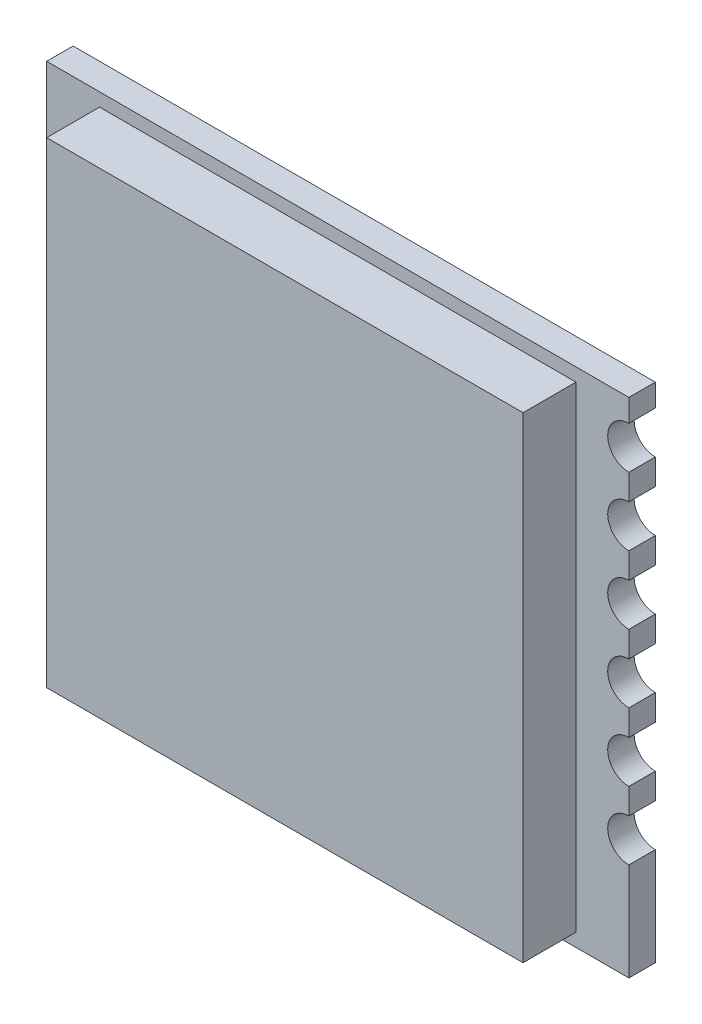
from build123d import *

# Parameters (mm, degrees)
SKETCH_1_W          = 22
SKETCH_1_H          = 19
EXTRUDE_1_DEPTH     = 1
SKETCH_2_W          = 18
SKETCH_2_H          = 18
EXTRUDE_2_DEPTH     = 2
CUT_EXTRUDE_1_DEPTH = 4


with BuildPart() as part:
    # Эскиз1 → Бобышка-Вытянуть1 (new body)
    with BuildSketch(Plane.XY):
        Rectangle(SKETCH_1_W, SKETCH_1_H)
    extrude(amount=EXTRUDE_1_DEPTH)

    # Эскиз2 → Бобышка-Вытянуть2 (add)
    with BuildSketch(Plane.XY.offset(1)):
        Rectangle(SKETCH_2_W, SKETCH_2_H)
    extrude(amount=EXTRUDE_2_DEPTH)

    # Эскиз3 → Вырез-Вытянуть1 (cut, through all)
    with BuildSketch(Plane.XY.offset(3)):
        with BuildLine():
            Line((-11, -4.2), (-11, -5.8))
            ThreePointArc((-11, -5.8), (-10.2, -5), (-11, -4.2))
        make_face()
        with BuildLine():
            Line((-11, -1.63), (-11, -3.23))
            ThreePointArc((-11, -3.23), (-10.2, -2.43), (-11, -1.63))
        make_face()
        with BuildLine():
            Line((-11, 0.94), (-11, -0.66))
            ThreePointArc((-11, -0.66), (-10.2, 0.14), (-11, 0.94))
        make_face()
        with BuildLine():
            Line((-11, 3.51), (-11, 1.91))
            ThreePointArc((-11, 1.91), (-10.2, 2.71), (-11, 3.51))
        make_face()
        with BuildLine():
            Line((-11, 6.08), (-11, 4.48))
            ThreePointArc((-11, 4.48), (-10.2, 5.28), (-11, 6.08))
        make_face()
        with BuildLine():
            Line((11, -4.2), (11, -5.8))
            ThreePointArc((11, -5.8), (10.2, -5), (11, -4.2))
        make_face()
        with BuildLine():
            Line((11, -1.63), (11, -3.23))
            ThreePointArc((11, -3.23), (10.2, -2.43), (11, -1.63))
        make_face()
        with BuildLine():
            Line((11, 0.94), (11, -0.66))
            ThreePointArc((11, -0.66), (10.2, 0.14), (11, 0.94))
        make_face()
        with BuildLine():
            Line((11, 3.51), (11, 1.91))
            ThreePointArc((11, 1.91), (10.2, 2.71), (11, 3.51))
        make_face()
        with BuildLine():
            Line((11, 6.08), (11, 4.48))
            ThreePointArc((11, 4.48), (10.2, 5.28), (11, 6.08))
        make_face()
        with BuildLine():
            Line((11, 8.65), (11, 7.05))
            ThreePointArc((11, 7.05), (10.2, 7.85), (11, 8.65))
        make_face()
    extrude(amount=-CUT_EXTRUDE_1_DEPTH, mode=Mode.SUBTRACT)


solid = part.part
